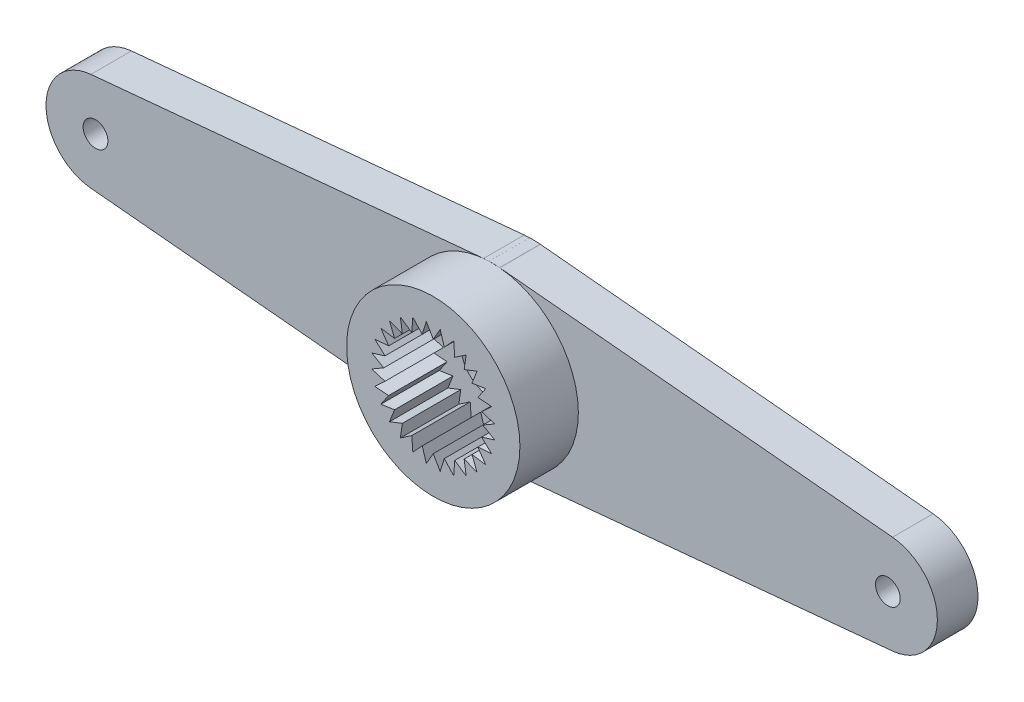
from build123d import *

# Parameters (mm, degrees)
SKETCH_1_R      = 1
EXTRUDE_1_DEPTH = 4.3
SKETCH_2_R      = 2
EXTRUDE_2_DEPTH = 1
EXTRUDE_3_DEPTH = 3.5
SKETCH_7_R      = 3.5
EXTRUDE_4_DEPTH = 4
SKETCH_9_R      = 0.5
EXTRUDE_5_DEPTH = 1.64


with BuildPart() as part:
    # 草图1 → 凸台-拉伸1 (new body)
    with BuildSketch(Plane.XY):
        Circle(SKETCH_1_R)
    extrude(amount=-EXTRUDE_1_DEPTH)

    # 草图2 → 凸台-拉伸2 (add)
    with BuildSketch(Plane.XY):
        Circle(SKETCH_2_R)
    extrude(amount=EXTRUDE_2_DEPTH)

    # 草图3 → 凸台-拉伸3 (add)
    with BuildSketch(Plane.XY.offset(1)):
        Polygon((2.359708326, -0.825697655), (1.801937736, -0.867767478), (2.116810498, -1.330080191), (1.563662965, -1.246979604), (1.767766953, -1.767766953), (1.246979604, -1.563662965), (1.330080191, -2.116810498), (0.867767478, -1.801937736), (0.825697655, -2.359708326), (0.445041868, -1.949855824), (0.27991119, -2.484280525), (0, -2), (-0.27991119, -2.484280525), (-0.445041868, -1.949855824), (-0.825697655, -2.359708326), (-0.867767478, -1.801937736), (-1.330080191, -2.116810498), (-1.246979604, -1.563662965), (-1.767766953, -1.767766953), (-1.563662965, -1.246979604), (-2.116810498, -1.330080191), (-1.801937736, -0.867767478), (-2.359708326, -0.825697655), (-1.949855824, -0.445041868), (-2.484280525, -0.27991119), (-2, 0), (-2.484280525, 0.27991119), (-1.949855824, 0.445041868), (-2.359708326, 0.825697655), (-1.801937736, 0.867767478), (-2.116810498, 1.330080191), (-1.563662965, 1.246979604), (-1.767766953, 1.767766953), (-1.246979604, 1.563662965), (-1.330080191, 2.116810498), (-0.867767478, 1.801937736), (-0.825697655, 2.359708326), (-0.445041868, 1.949855824), (-0.27991119, 2.484280525), (0, 2), (0.27991119, 2.484280525), (0.445041868, 1.949855824), (0.825697655, 2.359708326), (0.867767478, 1.801937736), (1.330080191, 2.116810498), (1.246979604, 1.563662965), (1.767766953, 1.767766953), (1.563662965, 1.246979604), (2.116810498, 1.330080191), (1.801937736, 0.867767478), (2.359708326, 0.825697655), (1.949855824, 0.445041868), (2.484280525, 0.27991119), (2, 0), (2.484280525, -0.27991119), (1.949855824, -0.445041868), align=None)
    extrude(amount=EXTRUDE_3_DEPTH)


with BuildPart() as body_2:
    # 草图7 → 凸台-拉伸4 (new body)
    with BuildSketch(Plane.XY.offset(4.5)):
        Circle(SKETCH_7_R)
    extrude(amount=-EXTRUDE_4_DEPTH)

    # Combine 1: cut part
    add(part.part, mode=Mode.SUBTRACT)


with BuildPart() as body_2_2:
    # 草图9 → 凸台-拉伸5 (new body)
    with BuildSketch(Plane(origin=(0, 0, 0.5), x_dir=(-1, 0, 0), z_dir=(0, 0, -1))):
        with BuildLine():
            Line((-16.187500002, 1.991191539), (-0.328125, 3.484585195))
            ThreePointArc((-0.328125, 3.484585195), (0, 3.5), (0.328125, 3.484585195))
            Line((0.328125, 3.484585195), (16.187500002, 1.991191539))
            ThreePointArc((16.187500002, 1.991191539), (17.999999999, -1e-09), (16.1875, -1.99119154))
            Line((16.1875, -1.99119154), (0.328125, -3.484585195))
            ThreePointArc((0.328125, -3.484585195), (0, -3.5), (-0.328125, -3.484585195))
            Line((-0.328125, -3.484585195), (-16.1875, -1.99119154))
            ThreePointArc((-16.1875, -1.99119154), (-17.999999999, -1e-09), (-16.187500002, 1.991191539))
        make_face()
        with Locations((16, 0)):
            Circle(SKETCH_9_R, mode=Mode.SUBTRACT)
        with Locations((-16, 0)):
            Circle(SKETCH_9_R, mode=Mode.SUBTRACT)
    extrude(amount=-EXTRUDE_5_DEPTH)


with BuildPart() as hole_wizard_m2_1_tool:
    # 草图12 → M2 六角凹头螺钉的柱形沉头孔1 (revolve)
    with BuildSketch(Plane(origin=(0, 0, 0.5), x_dir=(0, 1, 0), z_dir=(1, 0, 0))):
        Polygon((0, 0), (0, 4), (1.25, 3.248924226), (1.25, 0.9), (2.4, 0.9), (2.4, 0), align=None)
    revolve(axis=Axis((0, 0, -5.85), (0, 0, 1)))


with BuildPart() as body_2_1:
    add(body_2.part)

    # M2 六角凹头螺钉的柱形沉头孔1: cut by hole_wizard_m2_1_tool
    add(hole_wizard_m2_1_tool.part, mode=Mode.SUBTRACT)


with BuildPart() as body_2_2_1:
    add(body_2_2.part)

    # M2 六角凹头螺钉的柱形沉头孔1: cut by hole_wizard_m2_1_tool
    add(hole_wizard_m2_1_tool.part, mode=Mode.SUBTRACT)


solid = Compound([body_2_1.part, body_2_2_1.part])
